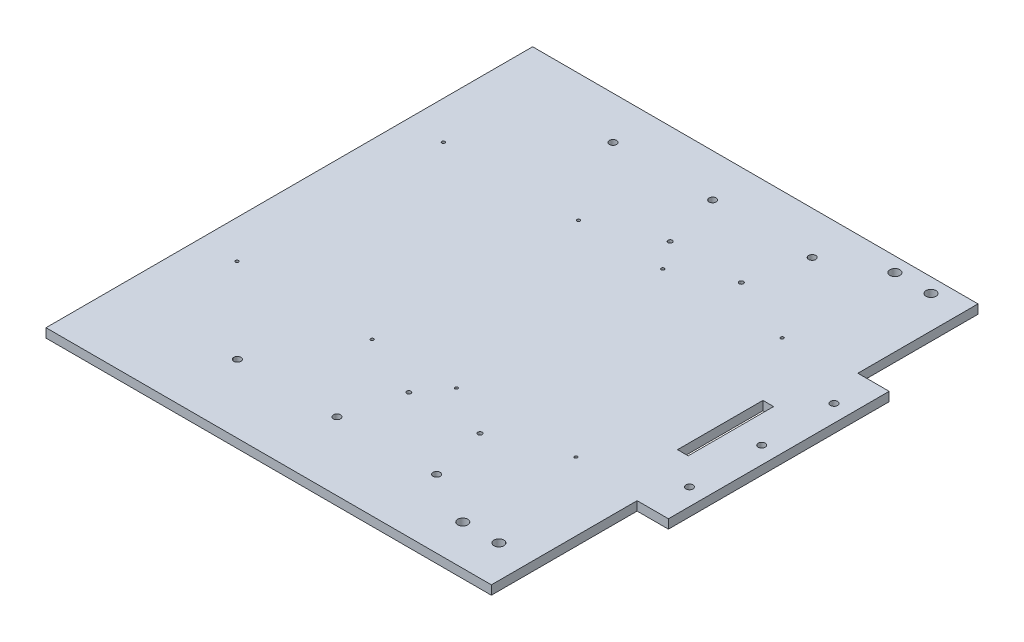
from build123d import *

# Parameters (mm, degrees)
SKETCH1_W           = 313
SKETCH1_H           = 342
BOSS_EXTRUDE1_DEPTH = 6.35
SKETCH3_W           = 22
SKETCH3_H           = 155.14040353
SKETCH3_R           = 2.5
BOSS_EXTRUDE2_DEPTH = 6.35
SKETCH2_R           = 2.5
CUT_EXTRUDE1_DEPTH  = 7.35
SKETCH4_R           = 3.5
CUT_EXTRUDE2_DEPTH  = 7.35
CUT_EXTRUDE3_DEPTH  = 7.35
SKETCH6_R           = 1.5
CUT_EXTRUDE4_DEPTH  = 7.35
SKETCH7_R           = 1.05
CUT_EXTRUDE5_DEPTH  = 7.35


with BuildPart() as part:
    # Sketch1 → Boss-Extrude1 (new body)
    with BuildSketch(Plane(origin=(0, 0, 0), x_dir=(1, 0, 0), z_dir=(0, 1, 0))):
        Rectangle(SKETCH1_W, SKETCH1_H)
    extrude(amount=-BOSS_EXTRUDE1_DEPTH)

    # Sketch3 → Boss-Extrude2 (add)
    with BuildSketch(Plane(origin=(0, 0, 0), x_dir=(1, 0, 0), z_dir=(0, 1, 0))):
        with Locations((167.5, 9)):
            Rectangle(SKETCH3_W, SKETCH3_H)
        with Locations((166.5, 9)):
            Circle(SKETCH3_R, mode=Mode.SUBTRACT)
        with Locations((166.5, -41.8)):
            Circle(SKETCH3_R, mode=Mode.SUBTRACT)
        with Locations((166.5, 59.8)):
            Circle(SKETCH3_R, mode=Mode.SUBTRACT)
    extrude(amount=-BOSS_EXTRUDE2_DEPTH)

    # Sketch2 → Cut-Extrude1 (cut, through all)
    with BuildSketch(Plane(origin=(0, 0, 0), x_dir=(1, 0, 0), z_dir=(0, 1, 0))):
        with Locations((0, -123)):
            Circle(SKETCH2_R)
        with Locations((-70, -123)):
            Circle(SKETCH2_R)
        with Locations((70, -123)):
            Circle(SKETCH2_R)
        with Locations((-70, 141)):
            Circle(SKETCH2_R)
        with Locations((0, 141)):
            Circle(SKETCH2_R)
        with Locations((70, 141)):
            Circle(SKETCH2_R)
    extrude(amount=-CUT_EXTRUDE1_DEPTH, mode=Mode.SUBTRACT)

    # Sketch4 → Cut-Extrude2 (cut, through all)
    with BuildSketch(Plane(origin=(0, 0, 0), x_dir=(1, 0, 0), z_dir=(0, 1, 0))):
        with Locations((133.64, 160.84)):
            Circle(SKETCH4_R)
        with Locations((108.24, 160.84)):
            Circle(SKETCH4_R)
    cut_extrude2 = extrude(amount=-CUT_EXTRUDE2_DEPTH, mode=Mode.SUBTRACT)

    # Mirror1: Cut-Extrude2 across plane
    add(cut_extrude2.mirror(Plane(origin=(0, 0, -9), x_dir=(1, 0, 0), z_dir=(0, 0, -1))), mode=Mode.SUBTRACT)

    # Sketch5 → Cut-Extrude3 (cut, through all)
    with BuildSketch(Plane(origin=(0, 0, 0), x_dir=(1, 0, 0), z_dir=(0, 1, 0))):
        Polygon((139.671773243, 36.673783491), (147.171773243, 36.673783491), (147.143523721, -23.326216509), (139.643523721, -23.326216509), align=None)
    extrude(amount=-CUT_EXTRUDE3_DEPTH, mode=Mode.SUBTRACT)

    # Sketch6 → Cut-Extrude4 (cut, through all)
    with BuildSketch(Plane(origin=(0, 0, 0), x_dir=(1, 0, 0), z_dir=(0, 1, 0))):
        with Locations((60.32, 100.82)):
            Circle(SKETCH6_R)
        with Locations((10.32, 100.82)):
            Circle(SKETCH6_R)
        with Locations((10.32, -82.82)):
            Circle(SKETCH6_R)
        with Locations((60.32, -82.82)):
            Circle(SKETCH6_R)
    extrude(amount=-CUT_EXTRUDE4_DEPTH, mode=Mode.SUBTRACT)

    # Sketch7 → Cut-Extrude5 (cut, through all)
    with BuildSketch(Plane(origin=(0, 0, 0), x_dir=(1, 0, 0), z_dir=(0, 1, 0))):
        with Locations((-34.742947475, 81.5)):
            Circle(SKETCH7_R)
        with Locations((-34.742947475, -63.5)):
            Circle(SKETCH7_R)
        with Locations((-129.742947475, 81.5)):
            Circle(SKETCH7_R)
        with Locations((-129.742947475, -63.5)):
            Circle(SKETCH7_R)
        with Locations((108.411541633, 81.5)):
            Circle(SKETCH7_R)
        with Locations((108.411541633, -63.5)):
            Circle(SKETCH7_R)
        with Locations((24.439359852, 81.5)):
            Circle(SKETCH7_R)
        with Locations((24.439359852, -63.5)):
            Circle(SKETCH7_R)
    extrude(amount=-CUT_EXTRUDE5_DEPTH, mode=Mode.SUBTRACT)


solid = part.part
